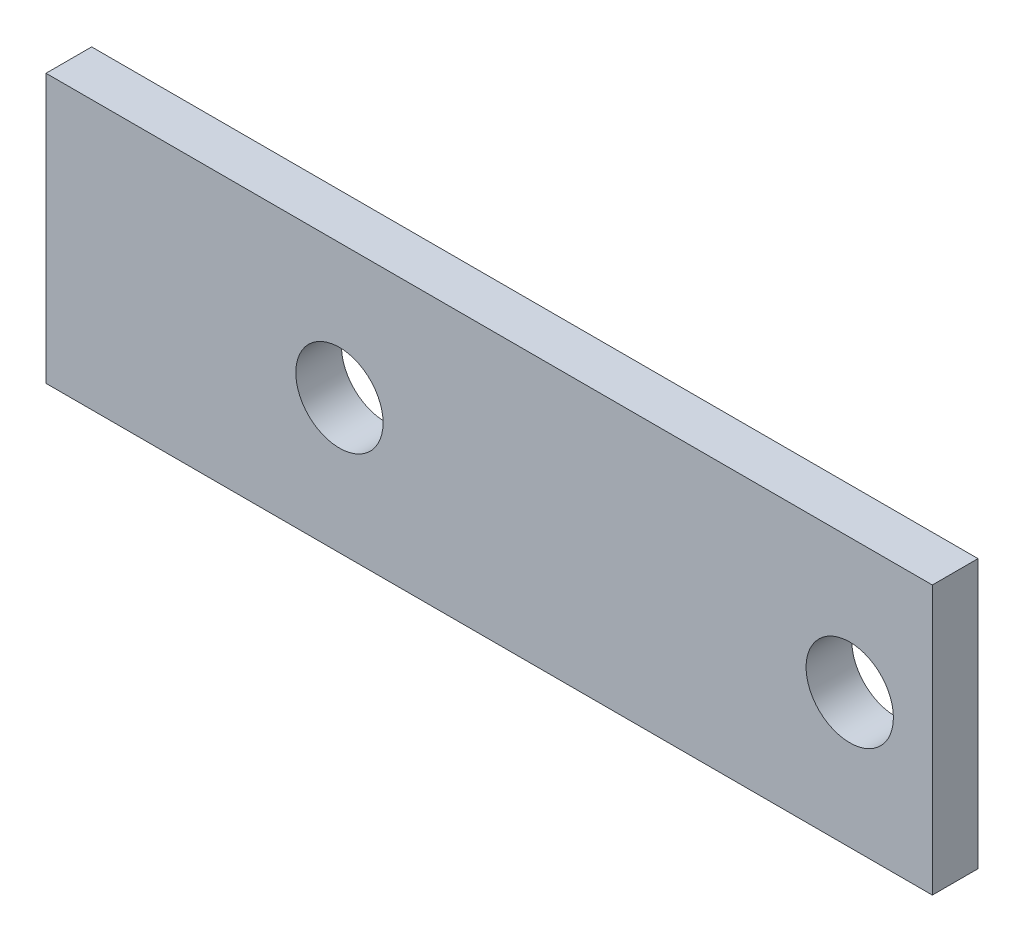
from build123d import *

# Parameters (mm, degrees)
ESBO_O1_W                = 33
ESBO_O1_H                = 10
RESSALTO_EXTRUS_O1_DEPTH = 1.7
ESBO_O2_R                = 1.625
CORTE_EXTRUS_O1_DEPTH    = 1.7


with BuildPart() as part:
    # Esboço1 → Ressalto-extrusão1 (new body)
    with BuildSketch(Plane.XY):
        Rectangle(ESBO_O1_W, ESBO_O1_H)
    extrude(amount=RESSALTO_EXTRUS_O1_DEPTH)

    # Esboço2 → Corte-extrusão1 (cut)
    with BuildSketch(Plane.XY.offset(1.7)):
        with Locations((13.425, 0)):
            Circle(ESBO_O2_R)
        with Locations((-5.575, 0)):
            Circle(ESBO_O2_R)
    extrude(amount=-CORTE_EXTRUS_O1_DEPTH, mode=Mode.SUBTRACT)


solid = part.part
